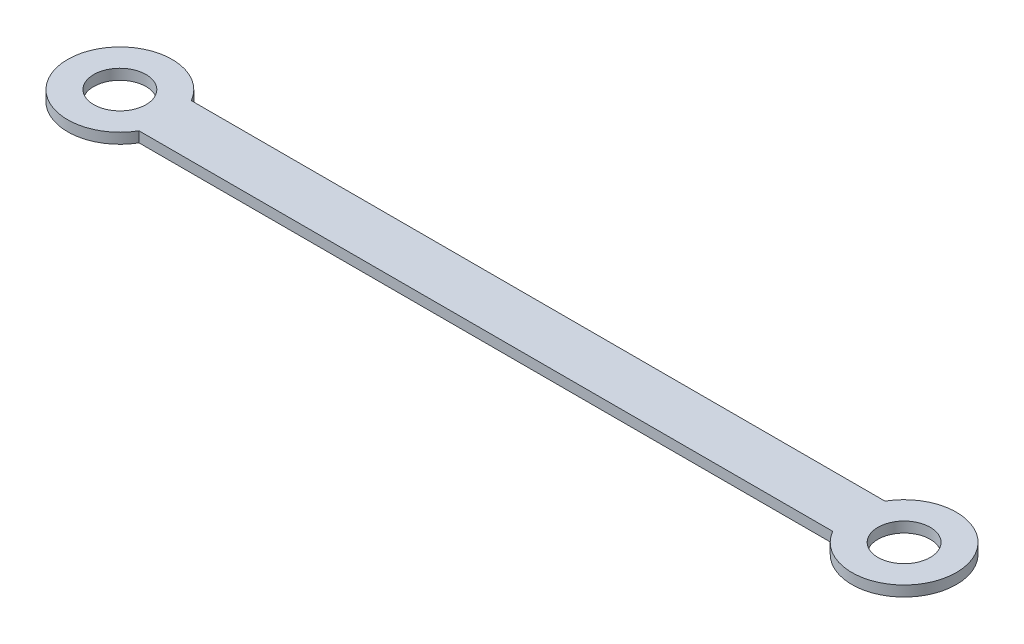
from build123d import *

# Parameters (mm, degrees)
SKETCH_5_R      = 5
EXTRUDE_1_DEPTH = 2


with BuildPart() as part:
    # 草圖5 → 填料-伸長1 (new body)
    with BuildSketch(Plane(origin=(0, 0, 0), x_dir=(1, 0, 0), z_dir=(0, 1, 0))):
        with BuildLine():
            Line((8.660254038, -5), (141.339745962, -5))
            ThreePointArc((141.339745962, -5), (160, 0), (141.339745962, 5))
            Line((141.339745962, 5), (8.660254038, 5))
            ThreePointArc((8.660254038, 5), (-10, 0), (8.660254038, -5))
        make_face()
        Circle(SKETCH_5_R, mode=Mode.SUBTRACT)
        with Locations((150, 0)):
            Circle(SKETCH_5_R, mode=Mode.SUBTRACT)
    extrude(amount=EXTRUDE_1_DEPTH)


solid = part.part
